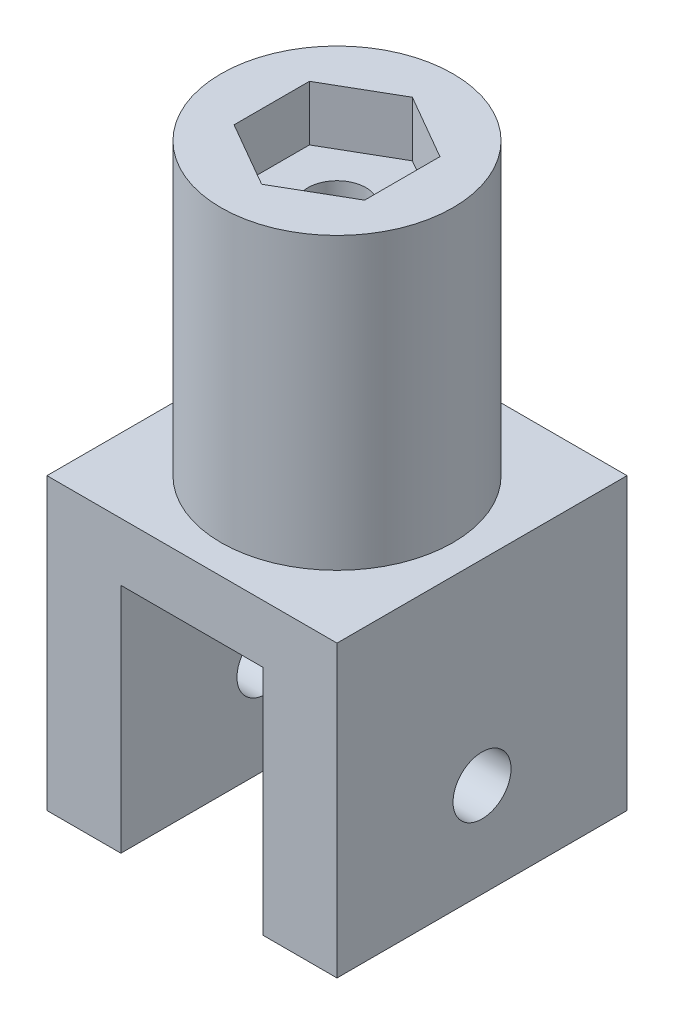
from build123d import *

# Parameters (mm, degrees)
SKETCH1_R           = 6.5
SKETCH1_R_2         = 2
BOSS_EXTRUDE1_DEPTH = 20
SKETCH6_W           = 20
SKETCH6_H           = 20
BOSS_EXTRUDE2_DEPTH = 4
SKETCH7_W           = 5.1
SKETCH7_H           = 20
BOSS_EXTRUDE3_DEPTH = 20
SKETCH8_R           = 2
CUT_EXTRUDE1_DEPTH  = 21
SKETCH14_R          = 8
SKETCH14_R_2        = 6.5
BOSS_EXTRUDE4_DEPTH = 20
CUT_EXTRUDE2_DEPTH  = 3.8


with BuildPart() as part:
    # Sketch1 → Boss-Extrude1 (new body)
    with BuildSketch(Plane(origin=(0, 0, 0), x_dir=(1, 0, 0), z_dir=(0, 1, 0))):
        Circle(SKETCH1_R)
        Circle(SKETCH1_R_2, mode=Mode.SUBTRACT)
    extrude(amount=BOSS_EXTRUDE1_DEPTH)

    # Sketch6 → Boss-Extrude2 (add)
    with BuildSketch(Plane.XZ):
        Rectangle(SKETCH6_W, SKETCH6_H)
    extrude(amount=BOSS_EXTRUDE2_DEPTH)

    # Sketch7 → Boss-Extrude3 (add)
    with BuildSketch(Plane.XY.offset(10)):
        with Locations((7.45, -10)):
            Rectangle(SKETCH7_W, SKETCH7_H)
        with Locations((-7.45, -10)):
            Rectangle(SKETCH7_W, SKETCH7_H)
    extrude(amount=-BOSS_EXTRUDE3_DEPTH)

    # Sketch8 → Cut-Extrude1 (cut, through all)
    with BuildSketch(Plane(origin=(10, 0, 0), x_dir=(0, 0, -1), z_dir=(1, 0, 0))):
        with Locations((0, -13.5)):
            Circle(SKETCH8_R)
    extrude(amount=-CUT_EXTRUDE1_DEPTH, mode=Mode.SUBTRACT)

    # Sketch14 → Boss-Extrude4 (add)
    with BuildSketch(Plane(origin=(0, 0, 0), x_dir=(1, 0, 0), z_dir=(0, 1, 0))):
        Circle(SKETCH14_R)
        Circle(SKETCH14_R_2, mode=Mode.SUBTRACT)
    extrude(amount=BOSS_EXTRUDE4_DEPTH)

    # Sketch15 → Cut-Extrude2 (cut)
    with BuildSketch(Plane(origin=(0, 20, 0), x_dir=(1, 0, 0), z_dir=(0, 1, 0))):
        Polygon((4.5, 2.598076211), (0, 5.196152423), (-4.5, 2.598076211), (-4.5, -2.598076211), (0, -5.196152423), (4.5, -2.598076211), align=None)
    extrude(amount=-CUT_EXTRUDE2_DEPTH, mode=Mode.SUBTRACT)


solid = part.part
